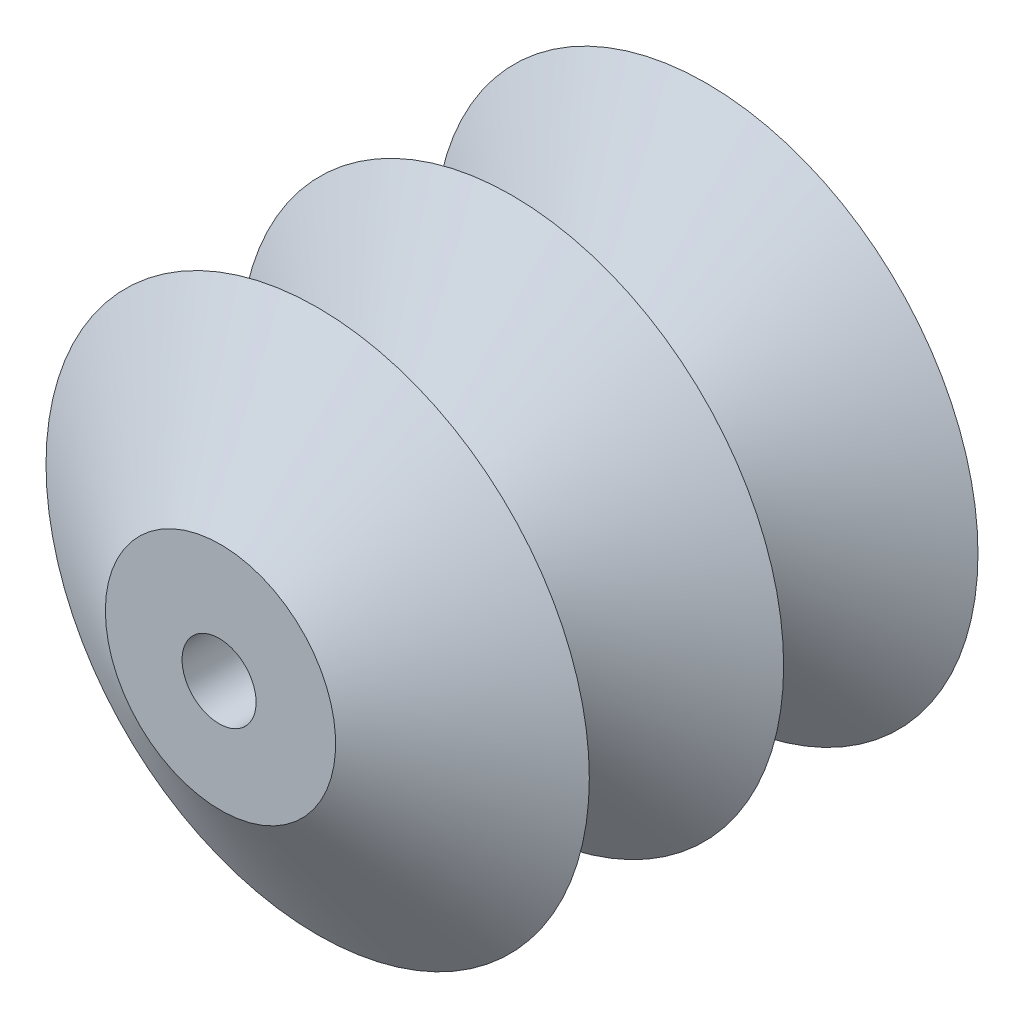
from build123d import *

# Parameters (mm, degrees)
TALADRO_DE_MARGEN_PARA_M81_D = 9


with BuildPart() as part:
    # Croquis1 → Revolución1 (revolve)
    with BuildSketch(Plane(origin=(0, 0, 0), x_dir=(1, 0, 0), z_dir=(0, 1, 0))):
        Polygon((0, 35.444139638), (0, -35.444139638), (14, -35.444139638), (33.031482218, -23.629426425), (14, -11.814713213), (33.031482218, 0), (14, 11.814713213), (33.031482218, 23.629426425), (14, 35.444139638), align=None)
    revolve(axis=Axis((0, 0, -35.444139638), (0, 0, 1)))

    # Taladro de margen para M81 (through all)
    with Locations(Plane.XY.offset(35.444139638)):
        with Locations((-0.173045489, -0.475875094)):
            Hole(TALADRO_DE_MARGEN_PARA_M81_D / 2)


solid = part.part
